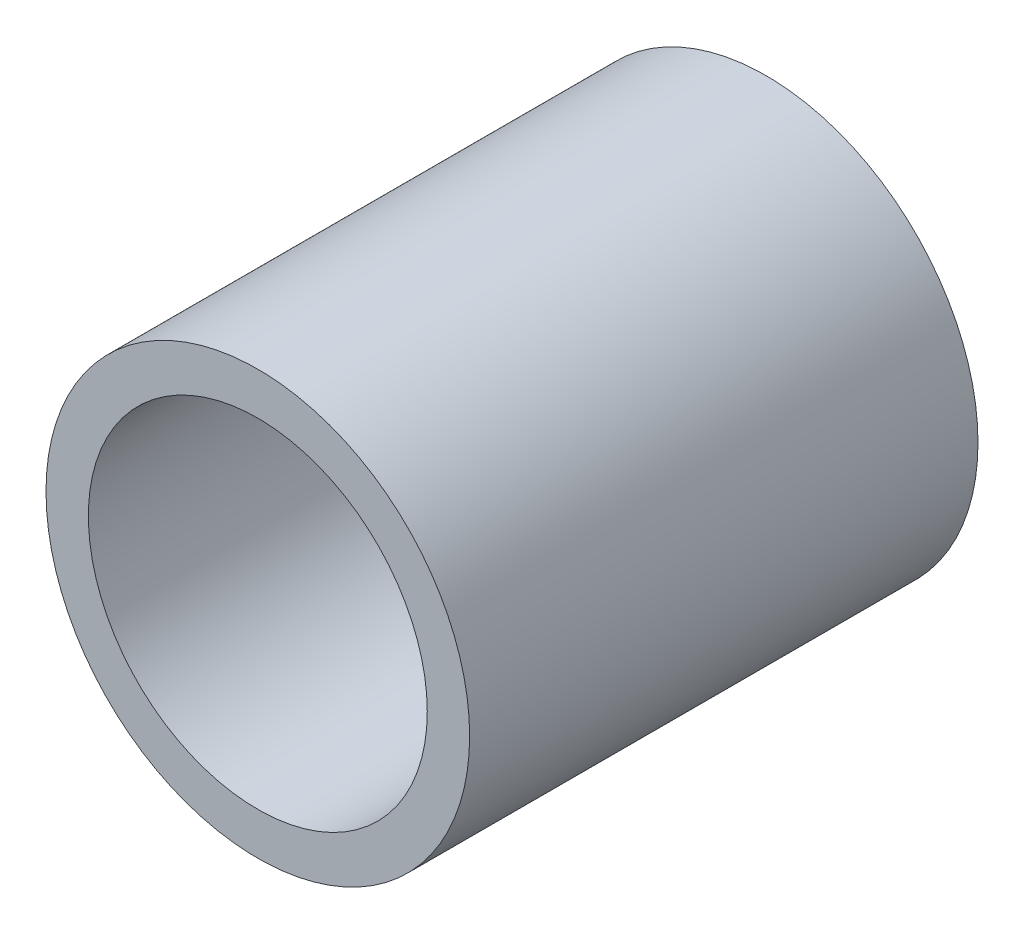
from build123d import *

# Parameters (mm, degrees)
SKETCH1_R           = 0.125
SKETCH1_R_2         = 0.1
BOSS_EXTRUDE1_DEPTH = 0.3


with BuildPart() as part:
    # Sketch1 → Boss-Extrude1 (new body)
    with BuildSketch(Plane.XY):
        Circle(SKETCH1_R)
        Circle(SKETCH1_R_2, mode=Mode.SUBTRACT)
    extrude(amount=BOSS_EXTRUDE1_DEPTH)


solid = part.part
